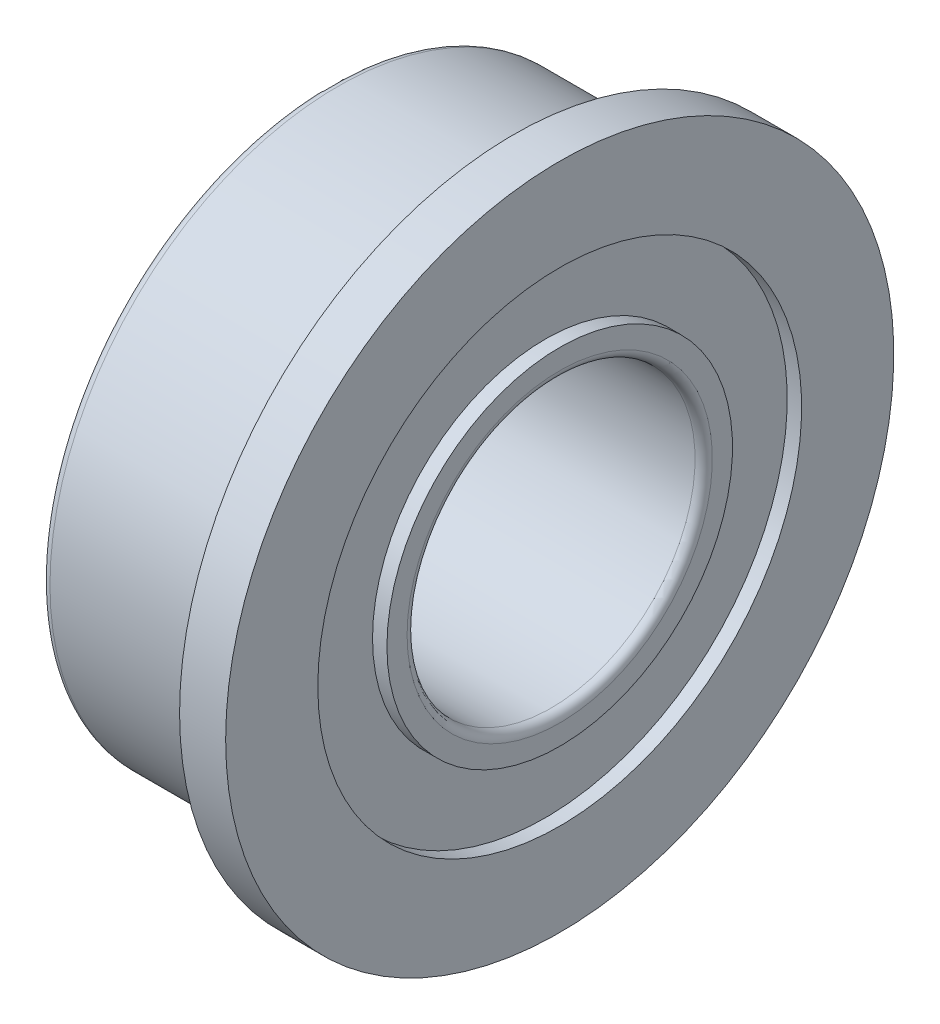
from build123d import *

# Parameters (mm, degrees)
FILLET1_R = 0.15


with BuildPart() as part:
    # Sketch1 → Revolve1 (revolve)
    with BuildSketch(Plane.XY):
        with BuildLine():
            Line((0, 5.2), (0, 5.8))
            Line((0, 5.8), (0.8, 5.8))
            Line((0.8, 5.8), (0.8, 4.2))
            Line((0.8, 4.2), (0.55, 4.2))
            Line((0.55, 4.2), (0.55, 3))
            Line((0.55, 3), (0.8, 3))
            Line((0.8, 3), (0.8, 2.5))
            Line((0.8, 2.5), (-3.2, 2.5))
            Line((-3.2, 2.5), (-3.2, 3))
            Line((-3.2, 3), (-2.95, 3))
            Line((-2.95, 3), (-2.95, 4.2))
            Line((-2.95, 4.2), (-3.2, 4.2))
            Line((-3.2, 4.2), (-3.2, 5))
            Line((-3.2, 5), (-0.2, 5))
            ThreePointArc((-0.2, 5), (0.141421356, 4.858578644), (0, 5.2))
        make_face()
    revolve(axis=Axis((-3.2, 0, 0), (1, 0, 0)))

    # Fillet1
    fillet1_edges = [part.edges().sort_by_distance(p)[0] for p in [
        (0.8, -2.5, 0),
        (-3.2, -2.5, 0),
        (-3.2, -5, 0),
    ]]
    fillet(fillet1_edges, radius=FILLET1_R)


solid = part.part
